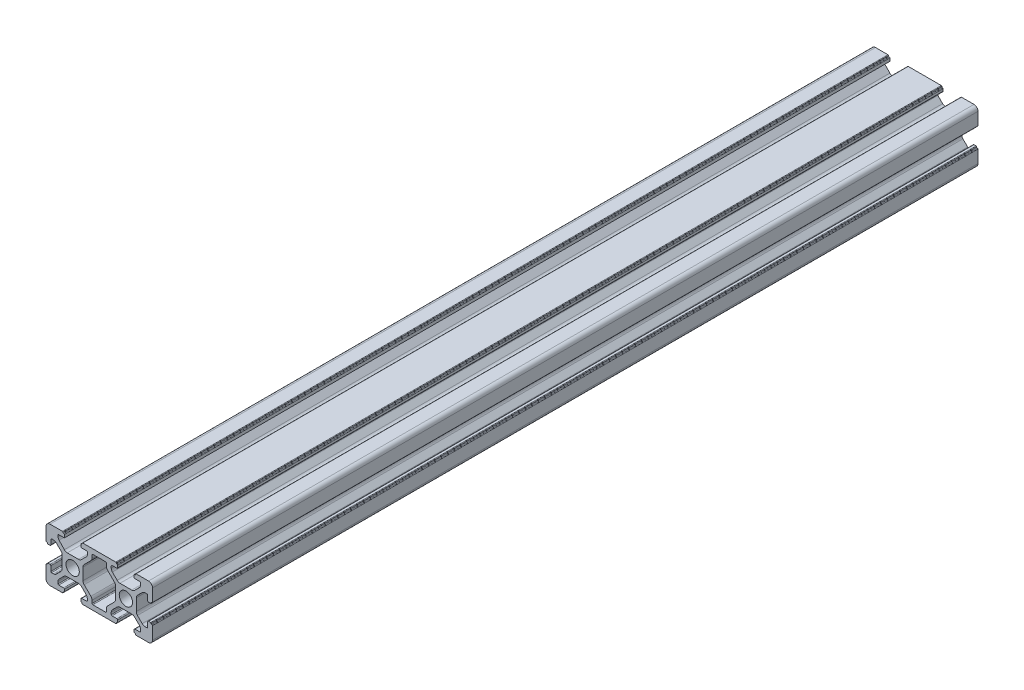
from build123d import *

# Parameters (mm, degrees)
SKETCH1_R             = 2.5
BOSS_EXTRUDE2_DEPTH   = 330
CROQUIS1_W            = 75.989981919
CROQUIS1_H            = 52.882015773
CORTAR_EXTRUIR1_DEPTH = 20


with BuildPart() as part:
    # Sketch1 → Boss-Extrude2 (new body)
    with BuildSketch(Plane.XY):
        with BuildLine():
            Line((1.5, 0), (6.2, 0))
            ThreePointArc((6.2, 0), (6.341421356, 0.058578644), (6.4, 0.2))
            Line((6.4, 0.2), (6.4, 0.3))
            ThreePointArc((6.4, 0.3), (6.458578644, 0.441421356), (6.6, 0.5))
            Line((6.6, 0.5), (6.7, 0.5))
            ThreePointArc((6.7, 0.5), (6.841421356, 0.558578644), (6.9, 0.7))
            Line((6.9, 0.7), (6.9, 1.5))
            ThreePointArc((6.9, 1.5), (6.812132034, 1.712132034), (6.6, 1.8))
            Line((6.6, 1.8), (4.8, 1.8))
            ThreePointArc((4.8, 1.8), (4.587867966, 1.887867966), (4.5, 2.1))
            Line((4.5, 2.1), (4.5, 2.818019485))
            ThreePointArc((4.5, 2.818019485), (4.614180701, 3.392044633), (4.939339828, 3.878679656))
            Line((4.939339828, 3.878679656), (6.721320344, 5.660660172))
            ThreePointArc((6.721320344, 5.660660172), (7.207955367, 5.985819299), (7.781980515, 6.1))
            Line((7.781980515, 6.1), (12.218019485, 6.1))
            ThreePointArc((12.218019485, 6.1), (12.792044633, 5.985819299), (13.278679656, 5.660660172))
            Line((13.278679656, 5.660660172), (15.060660172, 3.878679656))
            ThreePointArc((15.060660172, 3.878679656), (15.385819299, 3.392044633), (15.5, 2.818019485))
            Line((15.5, 2.818019485), (15.5, 2.1))
            ThreePointArc((15.5, 2.1), (15.412132034, 1.887867966), (15.2, 1.8))
            Line((15.2, 1.8), (13.4, 1.8))
            ThreePointArc((13.4, 1.8), (13.187867966, 1.712132034), (13.1, 1.5))
            Line((13.1, 1.5), (13.1, 0.7))
            ThreePointArc((13.1, 0.7), (13.158578644, 0.558578644), (13.3, 0.5))
            Line((13.3, 0.5), (13.4, 0.5))
            ThreePointArc((13.4, 0.5), (13.541421356, 0.441421356), (13.6, 0.3))
            Line((13.6, 0.3), (13.6, 0.2))
            ThreePointArc((13.6, 0.2), (13.658578644, 0.058578644), (13.8, 0))
            Line((13.8, 0), (26.2, 0))
            ThreePointArc((26.2, 0), (26.341421356, 0.058578644), (26.4, 0.2))
            Line((26.4, 0.2), (26.4, 0.3))
            ThreePointArc((26.4, 0.3), (26.458578644, 0.441421356), (26.6, 0.5))
            Line((26.6, 0.5), (26.7, 0.5))
            ThreePointArc((26.7, 0.5), (26.841421356, 0.558578644), (26.9, 0.7))
            Line((26.9, 0.7), (26.9, 1.5))
            ThreePointArc((26.9, 1.5), (26.812132034, 1.712132034), (26.6, 1.8))
            Line((26.6, 1.8), (24.8, 1.8))
            ThreePointArc((24.8, 1.8), (24.587867966, 1.887867966), (24.5, 2.1))
            Line((24.5, 2.1), (24.5, 2.818019485))
            ThreePointArc((24.5, 2.818019485), (24.614180701, 3.392044633), (24.939339828, 3.878679656))
            Line((24.939339828, 3.878679656), (26.721320344, 5.660660172))
            ThreePointArc((26.721320344, 5.660660172), (27.207955367, 5.985819299), (27.781980515, 6.1))
            Line((27.781980515, 6.1), (32.218019485, 6.1))
            ThreePointArc((32.218019485, 6.1), (32.792044633, 5.985819299), (33.278679656, 5.660660172))
            Line((33.278679656, 5.660660172), (35.060660172, 3.878679656))
            ThreePointArc((35.060660172, 3.878679656), (35.385819299, 3.392044633), (35.5, 2.818019485))
            Line((35.5, 2.818019485), (35.5, 2.1))
            ThreePointArc((35.5, 2.1), (35.412132034, 1.887867966), (35.2, 1.8))
            Line((35.2, 1.8), (33.4, 1.8))
            ThreePointArc((33.4, 1.8), (33.187867966, 1.712132034), (33.1, 1.5))
            Line((33.1, 1.5), (33.1, 0.7))
            ThreePointArc((33.1, 0.7), (33.158578644, 0.558578644), (33.3, 0.5))
            Line((33.3, 0.5), (33.4, 0.5))
            ThreePointArc((33.4, 0.5), (33.541421356, 0.441421356), (33.6, 0.3))
            Line((33.6, 0.3), (33.6, 0.2))
            ThreePointArc((33.6, 0.2), (33.658578644, 0.058578644), (33.8, 0))
            Line((33.8, 0), (38.5, 0))
            ThreePointArc((38.5, 0), (39.560660172, 0.439339828), (40, 1.5))
            Line((40, 1.5), (40, 6.2))
            ThreePointArc((40, 6.2), (39.941421356, 6.341421356), (39.8, 6.4))
            Line((39.8, 6.4), (39.7, 6.4))
            ThreePointArc((39.7, 6.4), (39.558578644, 6.458578644), (39.5, 6.6))
            Line((39.5, 6.6), (39.5, 6.7))
            ThreePointArc((39.5, 6.7), (39.441421356, 6.841421356), (39.3, 6.9))
            Line((39.3, 6.9), (38.5, 6.9))
            ThreePointArc((38.5, 6.9), (38.287867966, 6.812132034), (38.2, 6.6))
            Line((38.2, 6.6), (38.2, 4.8))
            ThreePointArc((38.2, 4.8), (38.112132034, 4.587867966), (37.9, 4.5))
            Line((37.9, 4.5), (37.181980515, 4.5))
            ThreePointArc((37.181980515, 4.5), (36.607955367, 4.614180701), (36.121320344, 4.939339828))
            Line((36.121320344, 4.939339828), (34.339339828, 6.721320344))
            ThreePointArc((34.339339828, 6.721320344), (34.014180701, 7.207955367), (33.9, 7.781980515))
            Line((33.9, 7.781980515), (33.9, 12.218019485))
            ThreePointArc((33.9, 12.218019485), (34.014180701, 12.792044633), (34.339339828, 13.278679656))
            Line((34.339339828, 13.278679656), (36.121320344, 15.060660172))
            ThreePointArc((36.121320344, 15.060660172), (36.607955367, 15.385819299), (37.181980515, 15.5))
            Line((37.181980515, 15.5), (37.9, 15.5))
            ThreePointArc((37.9, 15.5), (38.112132034, 15.412132034), (38.2, 15.2))
            Line((38.2, 15.2), (38.2, 13.4))
            ThreePointArc((38.2, 13.4), (38.287867966, 13.187867966), (38.5, 13.1))
            Line((38.5, 13.1), (39.3, 13.1))
            ThreePointArc((39.3, 13.1), (39.441421356, 13.158578644), (39.5, 13.3))
            Line((39.5, 13.3), (39.5, 13.4))
            ThreePointArc((39.5, 13.4), (39.558578644, 13.541421356), (39.7, 13.6))
            Line((39.7, 13.6), (39.8, 13.6))
            ThreePointArc((39.8, 13.6), (39.941421356, 13.658578644), (40, 13.8))
            Line((40, 13.8), (40, 18.5))
            ThreePointArc((40, 18.5), (39.560660172, 19.560660172), (38.5, 20))
            Line((38.5, 20), (33.8, 20))
            ThreePointArc((33.8, 20), (33.658578644, 19.941421356), (33.6, 19.8))
            Line((33.6, 19.8), (33.6, 19.7))
            ThreePointArc((33.6, 19.7), (33.541421356, 19.558578644), (33.4, 19.5))
            Line((33.4, 19.5), (33.3, 19.5))
            ThreePointArc((33.3, 19.5), (33.158578644, 19.441421356), (33.1, 19.3))
            Line((33.1, 19.3), (33.1, 18.5))
            ThreePointArc((33.1, 18.5), (33.187867966, 18.287867966), (33.4, 18.2))
            Line((33.4, 18.2), (35.2, 18.2))
            ThreePointArc((35.2, 18.2), (35.412132034, 18.112132034), (35.5, 17.9))
            Line((35.5, 17.9), (35.5, 17.181980515))
            ThreePointArc((35.5, 17.181980515), (35.385819299, 16.607955367), (35.060660172, 16.121320344))
            Line((35.060660172, 16.121320344), (33.278679656, 14.339339828))
            ThreePointArc((33.278679656, 14.339339828), (32.792044633, 14.014180701), (32.218019485, 13.9))
            Line((32.218019485, 13.9), (27.781980515, 13.9))
            ThreePointArc((27.781980515, 13.9), (27.207955367, 14.014180701), (26.721320344, 14.339339828))
            Line((26.721320344, 14.339339828), (24.939339828, 16.121320344))
            ThreePointArc((24.939339828, 16.121320344), (24.614180701, 16.607955367), (24.5, 17.181980515))
            Line((24.5, 17.181980515), (24.5, 17.9))
            ThreePointArc((24.5, 17.9), (24.587867966, 18.112132034), (24.8, 18.2))
            Line((24.8, 18.2), (26.6, 18.2))
            ThreePointArc((26.6, 18.2), (26.812132034, 18.287867966), (26.9, 18.5))
            Line((26.9, 18.5), (26.9, 19.3))
            ThreePointArc((26.9, 19.3), (26.841421356, 19.441421356), (26.7, 19.5))
            Line((26.7, 19.5), (26.6, 19.5))
            ThreePointArc((26.6, 19.5), (26.458578644, 19.558578644), (26.4, 19.7))
            Line((26.4, 19.7), (26.4, 19.8))
            ThreePointArc((26.4, 19.8), (26.341421356, 19.941421356), (26.2, 20))
            Line((26.2, 20), (13.8, 20))
            ThreePointArc((13.8, 20), (13.658578644, 19.941421356), (13.6, 19.8))
            Line((13.6, 19.8), (13.6, 19.7))
            ThreePointArc((13.6, 19.7), (13.541421356, 19.558578644), (13.4, 19.5))
            Line((13.4, 19.5), (13.3, 19.5))
            ThreePointArc((13.3, 19.5), (13.158578644, 19.441421356), (13.1, 19.3))
            Line((13.1, 19.3), (13.1, 18.2))
            Line((13.1, 18.2), (15.3, 18.2))
            ThreePointArc((15.3, 18.2), (15.512132034, 18.112132034), (15.6, 17.9))
            Line((15.6, 17.9), (15.6, 17.281980515))
            ThreePointArc((15.6, 17.281980515), (15.485819299, 16.707955367), (15.160660172, 16.221320344))
            Line((15.160660172, 16.221320344), (13.278679656, 14.339339828))
            ThreePointArc((13.278679656, 14.339339828), (12.792044633, 14.014180701), (12.218019485, 13.9))
            Line((12.218019485, 13.9), (7.986375635, 13.9))
            ThreePointArc((7.986375635, 13.9), (7.393381044, 14.022191082), (6.896997987, 14.36885678))
            Line((6.896997987, 14.36885678), (4.910622352, 16.467414163))
            ThreePointArc((4.910622352, 16.467414163), (4.606431474, 16.943609851), (4.5, 17.498557383))
            Line((4.5, 17.498557383), (4.5, 17.9))
            ThreePointArc((4.5, 17.9), (4.587867966, 18.112132034), (4.8, 18.2))
            Line((4.8, 18.2), (6.9, 18.2))
            Line((6.9, 18.2), (6.9, 19.3))
            ThreePointArc((6.9, 19.3), (6.841421356, 19.441421356), (6.7, 19.5))
            Line((6.7, 19.5), (6.6, 19.5))
            ThreePointArc((6.6, 19.5), (6.458578644, 19.558578644), (6.4, 19.7))
            Line((6.4, 19.7), (6.4, 19.8))
            ThreePointArc((6.4, 19.8), (6.341421356, 19.941421356), (6.2, 20))
            Line((6.2, 20), (1.5, 20))
            ThreePointArc((1.5, 20), (0.439339828, 19.560660172), (0, 18.5))
            Line((0, 18.5), (0, 13.8))
            ThreePointArc((0, 13.8), (0.058578644, 13.658578644), (0.2, 13.6))
            Line((0.2, 13.6), (0.3, 13.6))
            ThreePointArc((0.3, 13.6), (0.441421356, 13.541421356), (0.5, 13.4))
            Line((0.5, 13.4), (0.5, 13.3))
            ThreePointArc((0.5, 13.3), (0.558578644, 13.158578644), (0.7, 13.1))
            Line((0.7, 13.1), (1.5, 13.1))
            ThreePointArc((1.5, 13.1), (1.712132034, 13.187867966), (1.8, 13.4))
            Line((1.8, 13.4), (1.8, 15.2))
            ThreePointArc((1.8, 15.2), (1.887867966, 15.412132034), (2.1, 15.5))
            Line((2.1, 15.5), (2.818019485, 15.5))
            ThreePointArc((2.818019485, 15.5), (3.392044633, 15.385819299), (3.878679656, 15.060660172))
            Line((3.878679656, 15.060660172), (5.660660172, 13.278679656))
            ThreePointArc((5.660660172, 13.278679656), (5.985819299, 12.792044633), (6.1, 12.218019485))
            Line((6.1, 12.218019485), (6.1, 7.781980515))
            ThreePointArc((6.1, 7.781980515), (5.985819299, 7.207955367), (5.660660172, 6.721320344))
            Line((5.660660172, 6.721320344), (3.878679656, 4.939339828))
            ThreePointArc((3.878679656, 4.939339828), (3.392044633, 4.614180701), (2.818019485, 4.5))
            Line((2.818019485, 4.5), (2.1, 4.5))
            ThreePointArc((2.1, 4.5), (1.887867966, 4.587867966), (1.8, 4.8))
            Line((1.8, 4.8), (1.8, 6.6))
            ThreePointArc((1.8, 6.6), (1.712132034, 6.812132034), (1.5, 6.9))
            Line((1.5, 6.9), (0.7, 6.9))
            ThreePointArc((0.7, 6.9), (0.558578644, 6.841421356), (0.5, 6.7))
            Line((0.5, 6.7), (0.5, 6.6))
            ThreePointArc((0.5, 6.6), (0.441421356, 6.458578644), (0.3, 6.4))
            Line((0.3, 6.4), (0.2, 6.4))
            ThreePointArc((0.2, 6.4), (0.058578644, 6.341421356), (0, 6.2))
            Line((0, 6.2), (0, 1.5))
            ThreePointArc((0, 1.5), (0.439339828, 0.439339828), (1.5, 0))
        make_face()
        with Locations((10, 10)):
            Circle(SKETCH1_R, mode=Mode.SUBTRACT)
        with Locations((30, 10)):
            Circle(SKETCH1_R, mode=Mode.SUBTRACT)
        with BuildLine():
            Line((17.6, 1.8), (22.4, 1.8))
            ThreePointArc((22.4, 1.8), (22.612132034, 1.887867966), (22.7, 2.1))
            Line((22.7, 2.1), (22.7, 3.139339828))
            ThreePointArc((22.7, 3.139339828), (22.814180701, 3.713364977), (23.139339828, 4.2))
            Line((23.139339828, 4.2), (25.660660172, 6.721320344))
            ThreePointArc((25.660660172, 6.721320344), (25.985819299, 7.207955367), (26.1, 7.781980515))
            Line((26.1, 7.781980515), (26.1, 12.218019485))
            ThreePointArc((26.1, 12.218019485), (25.985819299, 12.792044633), (25.660660172, 13.278679656))
            Line((25.660660172, 13.278679656), (23.139339828, 15.8))
            ThreePointArc((23.139339828, 15.8), (22.814180701, 16.286635023), (22.7, 16.860660172))
            Line((22.7, 16.860660172), (22.7, 17.9))
            ThreePointArc((22.7, 17.9), (22.612132034, 18.112132034), (22.4, 18.2))
            Line((22.4, 18.2), (17.6, 18.2))
            ThreePointArc((17.6, 18.2), (17.387867966, 18.112132034), (17.3, 17.9))
            Line((17.3, 17.9), (17.3, 16.860660172))
            ThreePointArc((17.3, 16.860660172), (17.185819299, 16.286635023), (16.860660172, 15.8))
            Line((16.860660172, 15.8), (14.339339828, 13.278679656))
            ThreePointArc((14.339339828, 13.278679656), (14.014180701, 12.792044633), (13.9, 12.218019485))
            Line((13.9, 12.218019485), (13.9, 7.781980515))
            ThreePointArc((13.9, 7.781980515), (14.014180701, 7.207955367), (14.339339828, 6.721320344))
            Line((14.339339828, 6.721320344), (16.860660172, 4.2))
            ThreePointArc((16.860660172, 4.2), (17.185819299, 3.713364977), (17.3, 3.139339828))
            Line((17.3, 3.139339828), (17.3, 2.1))
            ThreePointArc((17.3, 2.1), (17.387867966, 1.887867966), (17.6, 1.8))
        make_face(mode=Mode.SUBTRACT)
    extrude(amount=BOSS_EXTRUDE2_DEPTH)

    # Croquis1 → Cortar-Extruir1 (cut)
    with BuildSketch(Plane(origin=(0, 0, 0), x_dir=(-1, 0, 0), z_dir=(0, 0, -1))):
        with Locations((-20.846700052, 10.332421226)):
            Rectangle(CROQUIS1_W, CROQUIS1_H)
    extrude(amount=-CORTAR_EXTRUIR1_DEPTH, mode=Mode.SUBTRACT)


solid = part.part
